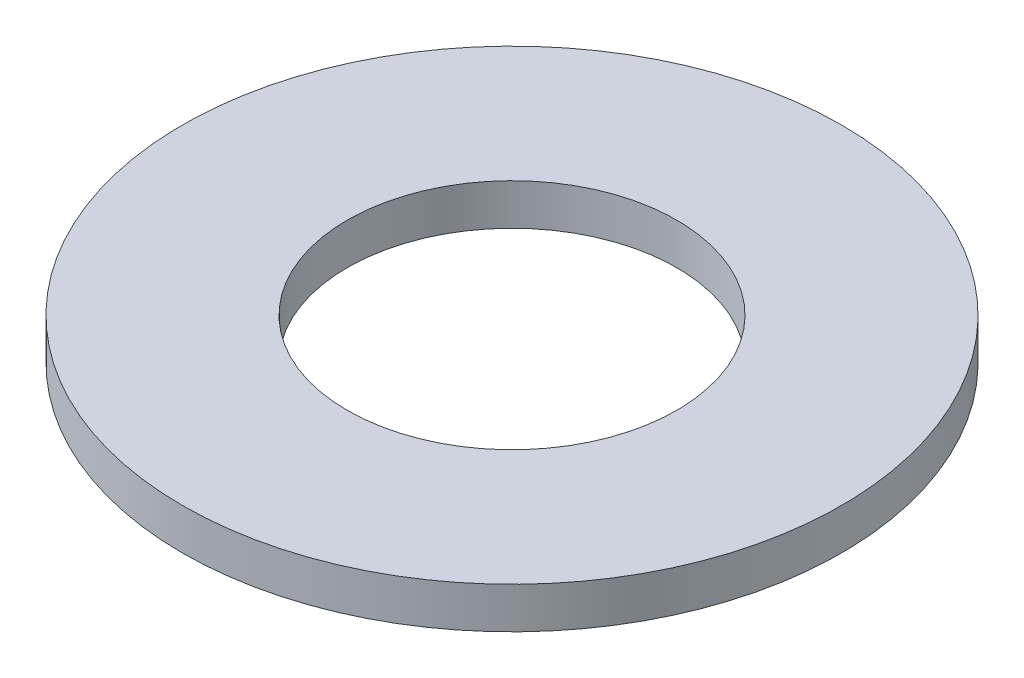
from build123d import *

# Parameters (mm, degrees)
SKETCH1_R           = 25.4
SKETCH1_R_2         = 12.7
BOSS_EXTRUDE1_DEPTH = 3.175


with BuildPart() as part:
    # Sketch1 → Boss-Extrude1 (new body)
    with BuildSketch(Plane(origin=(0, 0, 0), x_dir=(1, 0, 0), z_dir=(0, 1, 0))):
        Circle(SKETCH1_R)
        Circle(SKETCH1_R_2, mode=Mode.SUBTRACT)
    extrude(amount=BOSS_EXTRUDE1_DEPTH)


solid = part.part
